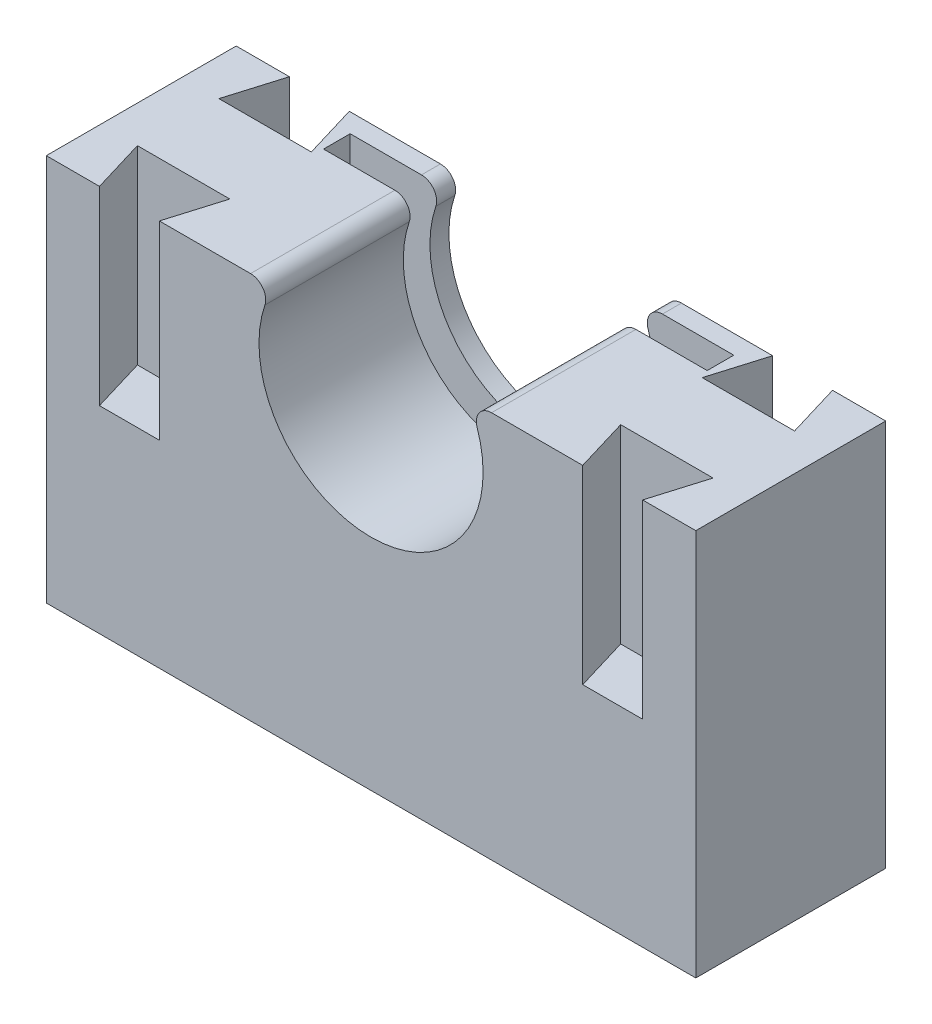
from build123d import *

# Parameters (mm, degrees)
BOSS_EXTRUDE1_DEPTH = 25
CUT_EXTRUDE3_START  = -25
SKETCH5_R           = 4.4
CUT_EXTRUDE3_DEPTH  = 4.5
SKETCH6_OUTSIDE_W   = 108.03
SKETCH6_OUTSIDE_H   = 47.53
CUT_EXTRUDE4_DEPTH  = 25
SKETCH8_W           = 50.5
SKETCH8_H           = 25.070079704
CUT_EXTRUDE5_DEPTH  = 3.5


with BuildPart() as part:
    # Sketch2 → Boss-Extrude1 (new body)
    with BuildSketch(Plane.XY):
        with BuildLine():
            Line((53.900497512, 28.014925373), (27.014667046, 28.014925373))
            ThreePointArc((27.014667046, 28.014925373), (25.389308303, 27.180347595), (25.120437848, 25.373134328))
            ThreePointArc((25.120437848, 25.373134328), (11.150497512, 5.889925373), (-2.819442823, 25.373134328))
            ThreePointArc((-2.819442823, 25.373134328), (-3.088313278, 27.180347595), (-4.713672021, 28.014925373))
            Line((-4.713672021, 28.014925373), (-31.599502488, 28.014925373))
            Line((-31.599502488, 28.014925373), (-31.599502488, -22.985074627))
            Line((-31.599502488, -22.985074627), (53.900497512, -22.985074627))
            Line((53.900497512, -22.985074627), (53.900497512, 28.014925373))
        make_face()
    extrude(amount=BOSS_EXTRUDE1_DEPTH)

    # Sketch5 → Cut-Extrude3 (cut)
    with BuildSketch(Plane.XY.offset(25).offset(CUT_EXTRUDE3_START)):
        with Locations((11.150497512, -2.910074627)):
            Circle(SKETCH5_R)
    extrude(amount=CUT_EXTRUDE3_DEPTH, mode=Mode.SUBTRACT)

    # Sketch6 outside → Cut-Extrude4 (cut)
    with BuildSketch(Plane(origin=(0, 28.014925373, 0), x_dir=(1, 0, 0), z_dir=(0, 1, 0))):
        with Locations((11.15, -12.5)):
            Rectangle(SKETCH6_OUTSIDE_W, SKETCH6_OUTSIDE_H)
        Polygon((-24.599502488, 0), (-26.73851519, -7.13632431), (-14.574659319, -7.13632431), (-16.713672021, 0), (-4.713672021, 0), (27.014667046, 0), (39.014667046, 0), (36.875076634, -7.136151124), (49.040087925, -7.136151124), (46.900497512, 0), (53.900497512, 0), (53.900497512, -25), (46.900497512, -25), (49.040087925, -17.863848876), (36.875076634, -17.863848876), (39.014667046, -25), (27.014667046, -25), (-4.713672021, -25), (-16.713672021, -25), (-14.574081609, -17.863848876), (-26.7390929, -17.863848876), (-24.599502488, -25), (-31.599502488, -25), (-31.599502488, 0), align=None, mode=Mode.SUBTRACT)
    extrude(amount=-CUT_EXTRUDE4_DEPTH, mode=Mode.SUBTRACT)

    # Sketch8 → Cut-Extrude5 (cut)
    with BuildSketch(Plane(origin=(0, 0, 2.5), x_dir=(-1, 0, 0), z_dir=(0, 0, -1))):
        with Locations((-11.150497512, 15.479885521)):
            Rectangle(SKETCH8_W, SKETCH8_H)
    extrude(amount=-CUT_EXTRUDE5_DEPTH, mode=Mode.SUBTRACT)


solid = part.part
